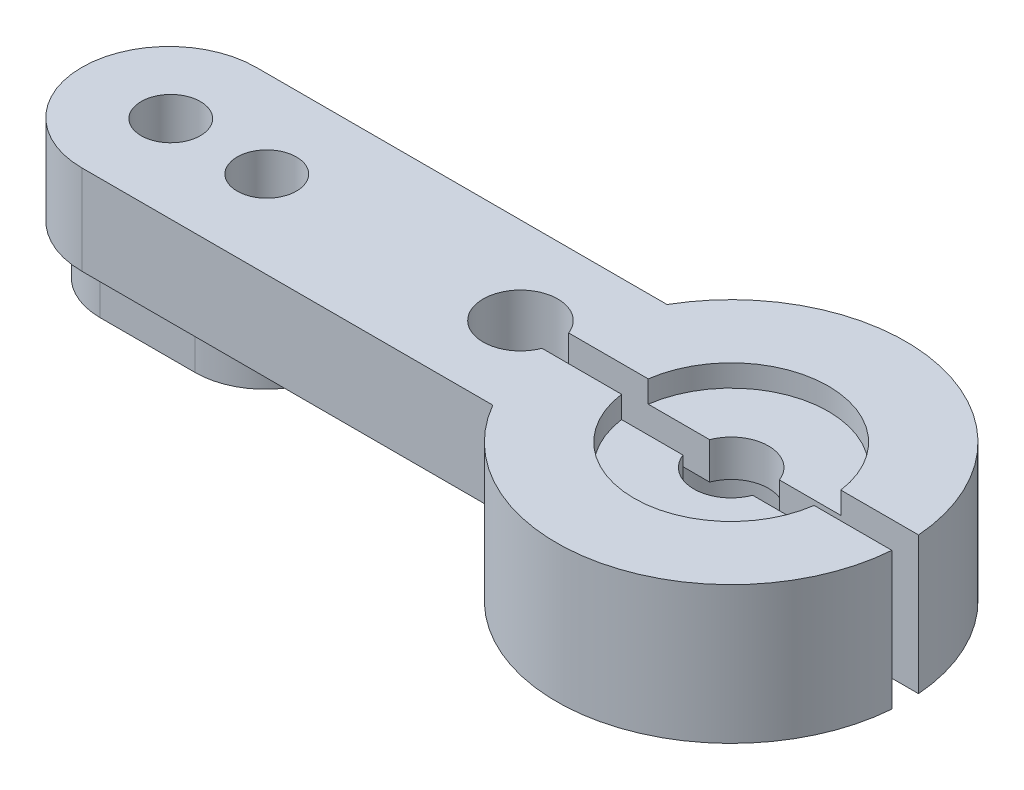
from build123d import *

# Parameters (mm, degrees)
SKETCH1_R           = 7.4803
BOSS_EXTRUDE1_DEPTH = 5.8928
SKETCH2_R           = 2.7813
CUT_EXTRUDE1_DEPTH  = 3.3782
BOSS_EXTRUDE2_DEPTH = 3.8354
BOSS_EXTRUDE3_DEPTH = 2.0574
SKETCH6_R           = 4.1656
CUT_EXTRUDE2_DEPTH  = 0.9398
SKETCH7_R           = 1.6002
SKETCH7_R_2         = 1.27
SKETCH7_W           = 18.255027212
SKETCH7_H           = 1.143
CUT_EXTRUDE3_DEPTH  = 6.8928


with BuildPart() as part:
    # Sketch1 → Boss-Extrude1 (new body)
    with BuildSketch(Plane(origin=(0, 0, 0), x_dir=(1, 0, 0), z_dir=(0, 1, 0))):
        Circle(SKETCH1_R)
    extrude(amount=BOSS_EXTRUDE1_DEPTH)

    # Sketch2 → Cut-Extrude1 (cut)
    with BuildSketch(Plane.XZ):
        Circle(SKETCH2_R)
    extrude(amount=-CUT_EXTRUDE1_DEPTH, mode=Mode.SUBTRACT)

    # Sketch4 → Boss-Extrude2 (add)
    with BuildSketch(Plane(origin=(0, 5.8928, 0), x_dir=(1, 0, 0), z_dir=(0, 1, 0))):
        with BuildLine():
            Line((-24.0919, 3.7338), (-6.481791855, 3.7338))
            ThreePointArc((-6.481791855, 3.7338), (-7.4803, 0), (-6.481791855, -3.7338))
            Line((-6.481791855, -3.7338), (-24.0919, -3.7338))
            ThreePointArc((-24.0919, -3.7338), (-27.8257, 0), (-24.0919, 3.7338))
        make_face()
    extrude(amount=-BOSS_EXTRUDE2_DEPTH)

    # Sketch5 → Boss-Extrude3 (add)
    with BuildSketch(Plane.XZ.offset(-2.0574)):
        with BuildLine():
            Line((-24.0284, 3.0099), (-19.9644, 3.0099))
            ThreePointArc((-19.9644, 3.0099), (-16.9545, 0), (-19.9644, -3.0099))
            Line((-19.9644, -3.0099), (-24.0284, -3.0099))
            ThreePointArc((-24.0284, -3.0099), (-27.0383, 0), (-24.0284, 3.0099))
        make_face()
    extrude(amount=BOSS_EXTRUDE3_DEPTH)

    # Sketch6 → Cut-Extrude2 (cut)
    with BuildSketch(Plane(origin=(0, 5.8928, 0), x_dir=(1, 0, 0), z_dir=(0, 1, 0))):
        Circle(SKETCH6_R)
    extrude(amount=-CUT_EXTRUDE2_DEPTH, mode=Mode.SUBTRACT)

    # Sketch7 → Cut-Extrude3 (cut, through all)
    with BuildSketch(Plane(origin=(0, 5.8928, 0), x_dir=(1, 0, 0), z_dir=(0, 1, 0))):
        with Locations((-9.0297, 0)):
            Circle(SKETCH7_R)
        Circle(SKETCH7_R)
        with Locations((-24.0157, 0)):
            Circle(SKETCH7_R_2)
        with Locations((-19.9009, 0)):
            Circle(SKETCH7_R_2)
        with Locations((0.097813606, 0)):
            Rectangle(SKETCH7_W, SKETCH7_H)
    extrude(amount=-CUT_EXTRUDE3_DEPTH, mode=Mode.SUBTRACT)


solid = part.part
